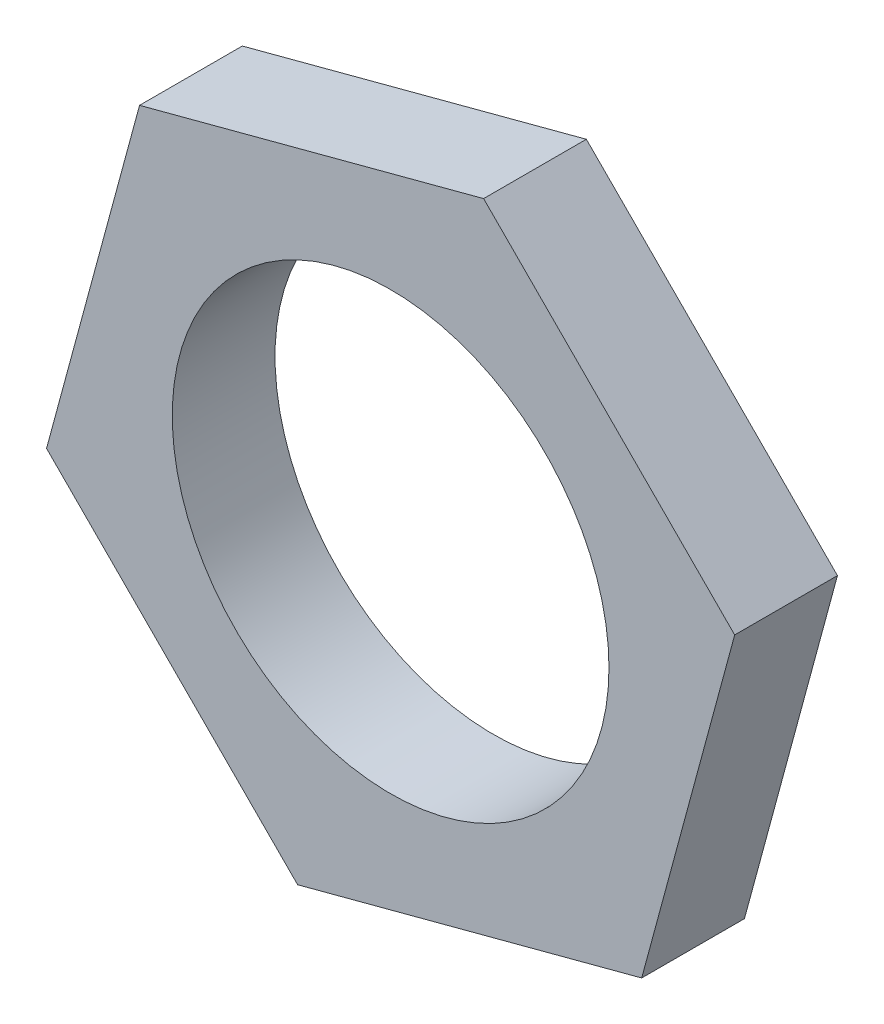
from build123d import *

# Parameters (mm, degrees)
SKETCH1_R           = 4.25
BOSS_EXTRUDE1_DEPTH = 2


with BuildPart() as part:
    # Sketch1 → Boss-Extrude1 (new body)
    with BuildSketch(Plane.XY):
        Polygon((4.886685994, -4.911242205), (6.696603511, 1.776373109), (1.809917517, 6.687615314), (-4.886685994, 4.911242205), (-6.696603511, -1.776373109), (-1.809917517, -6.687615314), align=None)
        Circle(SKETCH1_R, mode=Mode.SUBTRACT)
    extrude(amount=BOSS_EXTRUDE1_DEPTH)


solid = part.part
